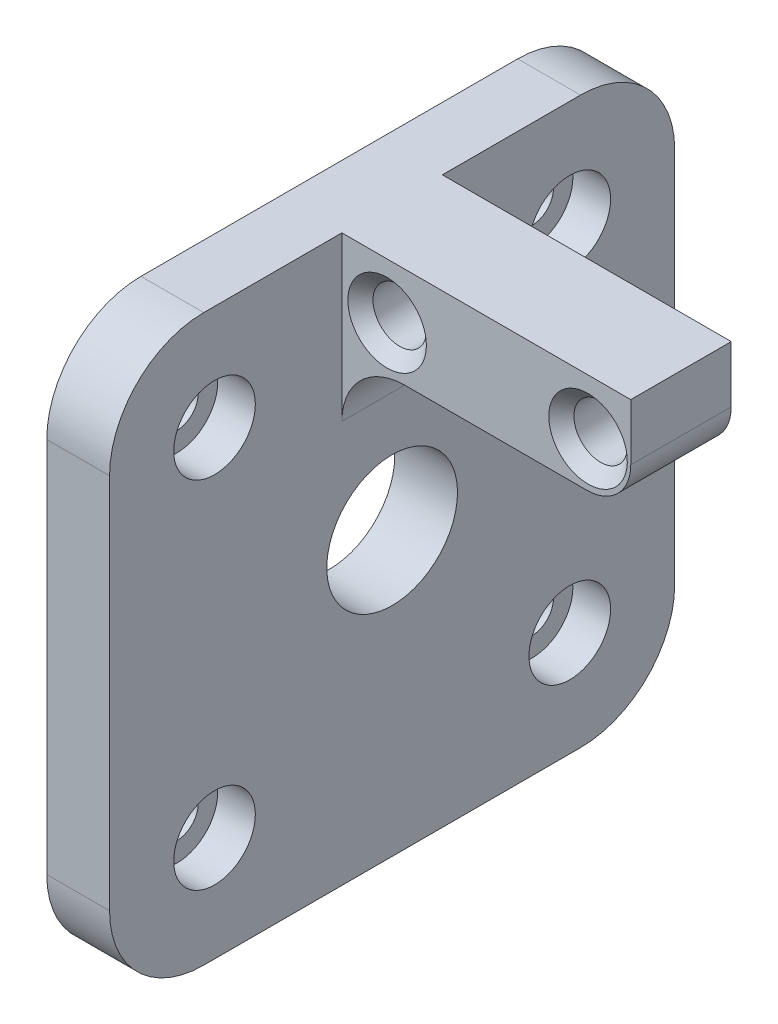
from build123d import *

# Parameters (mm, degrees)
SKETCH1_W                      = 45
SKETCH1_H                      = 45
SKETCH1_R                      = 5.205
BOSS_EXTRUDE1_DEPTH            = 5
SKETCH1_3_W                    = 8
SKETCH1_3_H                    = 8
BOSS_EXTRUDE2_DEPTH            = 28
FILLET1_R                      = 7.5
FILLET2_R                      = 5
FILLET3_R                      = 3.5
CUT_EXTRUDE1_DEPTH             = 43.385138905
CUT_EXTRUDE1_DEPTH_BACK        = 43.385138905
SKETCH2_R                      = 2.125
CBORE_FOR_M3_SHCS1_D           = 3.4
CBORE_FOR_M3_SHCS1_CBORE_D     = 6.5
CBORE_FOR_M3_SHCS1_CBORE_DEPTH = 3
CHAMFER1_SIZE                  = 1


with BuildPart() as part:
    # Sketch1 → Boss-Extrude1 (new body)
    with BuildSketch(Plane(origin=(0, 0, 0), x_dir=(0, 0, -1), z_dir=(1, 0, 0))):
        Rectangle(SKETCH1_W, SKETCH1_H)
        Circle(SKETCH1_R, mode=Mode.SUBTRACT)
    extrude(amount=BOSS_EXTRUDE1_DEPTH)

    # Sketch1_3 → Boss-Extrude2 (add)
    with BuildSketch(Plane(origin=(0, 0, 0), x_dir=(0, 0, -1), z_dir=(1, 0, 0))):
        with Locations((0, 18.5)):
            Rectangle(SKETCH1_3_W, SKETCH1_3_H)
    extrude(amount=BOSS_EXTRUDE2_DEPTH)

    # Fillet1
    fillet1_edges = [part.edges().sort_by_distance(p)[0] for p in [
        (2.5, -22.5, 22.5),
        (2.5, -22.5, -22.5),
        (2.5, 22.5, -22.5),
        (2.5, 22.5, 22.5),
    ]]
    fillet(fillet1_edges, radius=FILLET1_R)

    # Fillet2
    fillet2_edges = [part.edges().sort_by_distance(p)[0] for p in [
        (5, 14.5, 0),
    ]]
    fillet(fillet2_edges, radius=FILLET2_R)

    # Fillet3
    fillet3_edges = [part.edges().sort_by_distance(p)[0] for p in [
        (28, 14.5, 0),
    ]]
    fillet(fillet3_edges, radius=FILLET3_R)

    # Sketch2 → Cut-Extrude1 (cut, two sides: drawn at the far end of the back side and taken through both)
    with BuildSketch(Plane.XY.offset(-CUT_EXTRUDE1_DEPTH_BACK)):
        with Locations((8.6, 18.1)):
            Circle(SKETCH2_R)
        with Locations((24.6, 18.1)):
            Circle(SKETCH2_R)
    extrude(amount=CUT_EXTRUDE1_DEPTH + CUT_EXTRUDE1_DEPTH_BACK, mode=Mode.SUBTRACT)

    # CBORE for M3 SHCS1 (through all)
    with Locations(Plane(origin=(5, 0, 0), x_dir=(0, 0, -1), z_dir=(1, 0, 0))):
        with Locations((-14.142135624, 14.142135624), (14.142135624, 14.142135624), (-14.142135624, -14.142135624), (14.142135624, -14.142135624)):
            CounterBoreHole(CBORE_FOR_M3_SHCS1_D / 2, CBORE_FOR_M3_SHCS1_CBORE_D / 2, CBORE_FOR_M3_SHCS1_CBORE_DEPTH)

    # Chamfer1
    chamfer1_edges = [part.edges().sort_by_distance(p)[0] for p in [
        (22.475, 18.1, 4),
        (6.475, 18.1, 4),
    ]]
    chamfer(chamfer1_edges, length=CHAMFER1_SIZE)


solid = part.part
